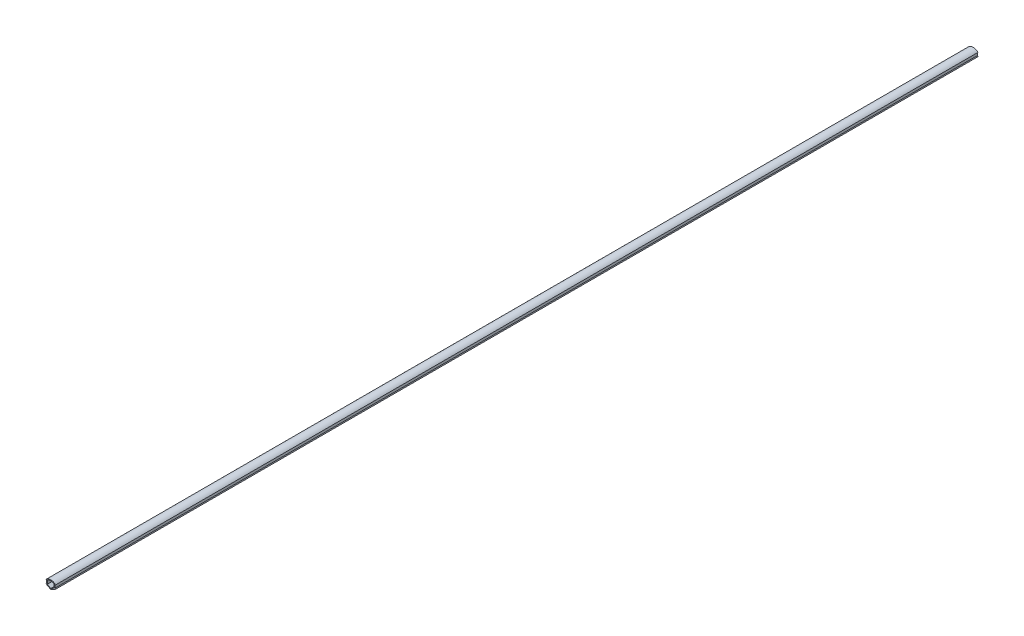
from build123d import *

# Parameters (mm, degrees)
EXTRUDE_1_DEPTH = 1000


with BuildPart() as part:
    # Эскиз1 → Бобышка-Вытянуть1 (new body)
    with BuildSketch(Plane.XY):
        with BuildLine():
            Line((0, 0), (-5.2, 3.0022214))
            Line((-5.2, 3.0022214), (-4.7, 3.868246804))
            Line((-4.7, 3.868246804), (-4.7, 7.074937186))
            Line((-4.7, 7.074937186), (-5.204805472, 7.074937186))
            ThreePointArc((-5.204805472, 7.074937186), (0, 9.3), (5.204805472, 7.074937186))
            Line((5.204805472, 7.074937186), (4.7, 7.074937186))
            Line((4.7, 7.074937186), (4.7, 3.868246804))
            Line((4.7, 3.868246804), (5.2, 3.0022214))
            Line((5.2, 3.0022214), (0, 0))
        make_face()
        with BuildLine():
            Line((0, 1.154700538), (-3.7, 3.290896534))
            Line((-3.7, 3.290896534), (-3.7, 7.074937186))
            ThreePointArc((-3.7, 7.074937186), (0, 8.3), (3.7, 7.074937186))
            Line((3.7, 7.074937186), (3.7, 3.290896534))
            Line((3.7, 3.290896534), (0, 1.154700538))
        make_face(mode=Mode.SUBTRACT)
    extrude(amount=EXTRUDE_1_DEPTH)


solid = part.part
